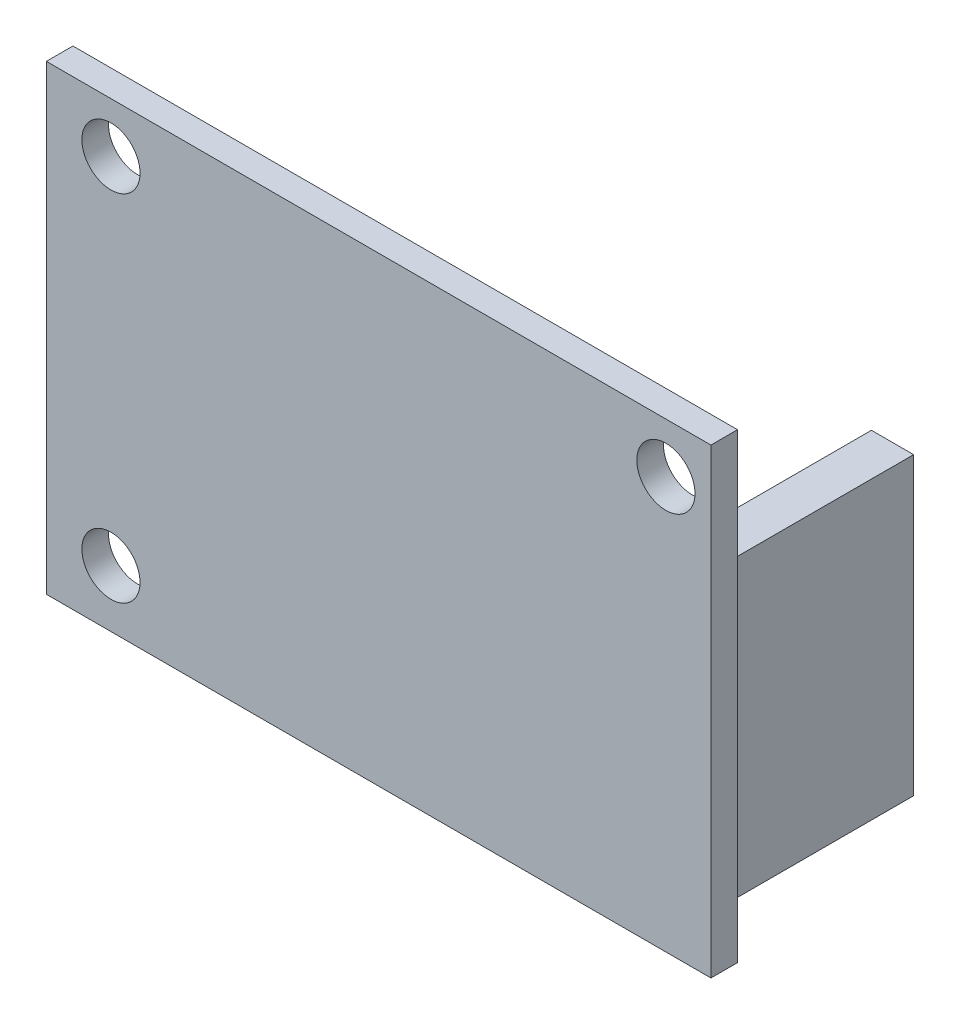
from build123d import *

# Parameters (mm, degrees)
SKETCH_1_W      = 2.54
SKETCH_1_H      = 17.78
EXTRUDE_1_DEPTH = 11
SKETCH_2_W      = 40
SKETCH_2_H      = 27.78
SKETCH_2_R      = 1.7500127
SKETCH_2_R_2    = 1.75
EXTRUDE_2_DEPTH = 1.6


with BuildPart() as part:
    # 草图1 → 凸台-拉伸1 (new body)
    with BuildSketch(Plane.XY):
        with Locations((-9.398018796, 46.482082804)):
            Rectangle(SKETCH_1_W, SKETCH_1_H)
    extrude(amount=EXTRUDE_1_DEPTH)

    # 草图2 → 凸台-拉伸2 (add)
    with BuildSketch(Plane.XY.offset(11)):
        with Locations((-27.728018796, 48.482082804)):
            Rectangle(SKETCH_2_W, SKETCH_2_H)
        with Locations((-10.439420879, 59.35991872)):
            Circle(SKETCH_2_R, mode=Mode.SUBTRACT)
        with Locations((-43.840487681, 59.35991872)):
            Circle(SKETCH_2_R_2, mode=Mode.SUBTRACT)
        with Locations((-43.840487681, 38.023876048)):
            Circle(SKETCH_2_R_2, mode=Mode.SUBTRACT)
    extrude(amount=EXTRUDE_2_DEPTH)


solid = part.part
